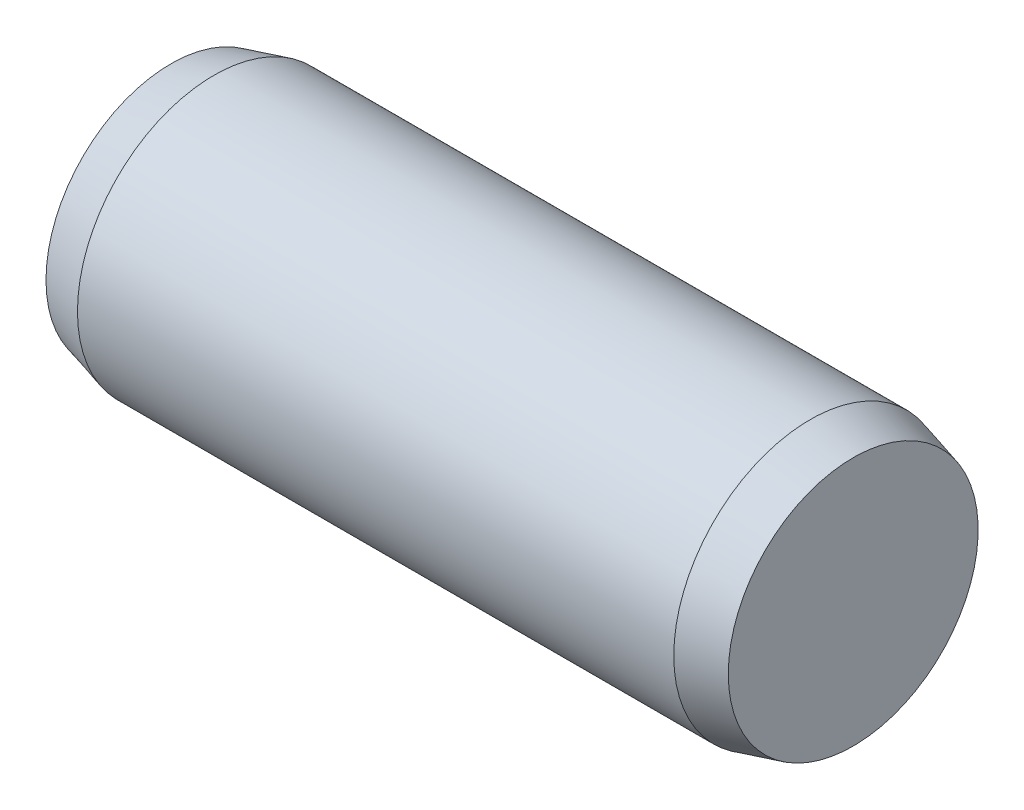
from build123d import *


with BuildPart() as part:
    # Sketch1 → Base-Revolve (revolve)
    with BuildSketch(Plane.XY):
        Polygon((0, 0), (10, 0), (10, 1.831192009), (9.37, 2), (0.63, 2), (0, 1.831192009), align=None)
    revolve(axis=Axis((-6.35, 0, 0), (1, 0, 0)))


solid = part.part
